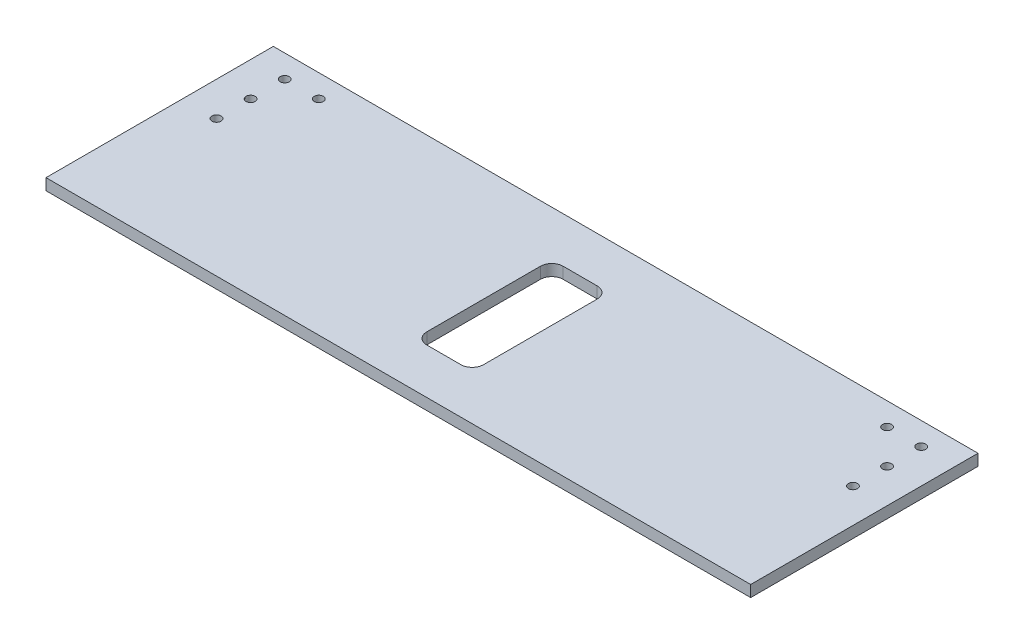
from build123d import *

# Parameters (mm, degrees)
SKETCH1_W           = 120
SKETCH1_H           = 95
SKETCH1_W_2         = 310
SKETCH1_H_2         = 100
BOSS_EXTRUDE1_DEPTH = 5
SKETCH2_R           = 2
SKETCH2_W           = 25
SKETCH2_H           = 60
CUT_EXTRUDE1_DEPTH  = 6
FILLET1_R           = 5
SKETCH5_W           = 80
SKETCH5_H           = 70
CUT_EXTRUDE2_DEPTH  = 5
CHAMFER1_SIZE       = 20
SKETCH6_W           = 95
SKETCH6_H           = 95
BOSS_EXTRUDE2_DEPTH = 5
SKETCH7_W           = 310
SKETCH7_H           = 95
CUT_EXTRUDE3_DEPTH  = 6


with BuildPart() as part:
    # Sketch1 → Boss-Extrude1 (new body)
    with BuildSketch(Plane(origin=(0, 0, 0), x_dir=(1, 0, 0), z_dir=(0, 1, 0))):
        with Locations((0, 97.5)):
            Rectangle(SKETCH1_W, SKETCH1_H)
        Rectangle(SKETCH1_W_2, SKETCH1_H_2)
    extrude(amount=BOSS_EXTRUDE1_DEPTH)

    # Sketch2 → Cut-Extrude1 (cut, through all)
    with BuildSketch(Plane(origin=(0, 5, 0), x_dir=(1, 0, 0), z_dir=(0, 1, 0))):
        with Locations((-140, 40)):
            Circle(SKETCH2_R)
        with Locations((-125, 40)):
            Circle(SKETCH2_R)
        with Locations((-140, 25)):
            Circle(SKETCH2_R)
        with Locations((-140, 10)):
            Circle(SKETCH2_R)
        with Locations((140, 10)):
            Circle(SKETCH2_R)
        with Locations((140, 25)):
            Circle(SKETCH2_R)
        with Locations((125, 40)):
            Circle(SKETCH2_R)
        with Locations((140, 40)):
            Circle(SKETCH2_R)
        with Locations((-50, 130)):
            Circle(SKETCH2_R)
        with Locations((50, 130)):
            Circle(SKETCH2_R)
        Rectangle(SKETCH2_W, SKETCH2_H)
    extrude(amount=-CUT_EXTRUDE1_DEPTH, mode=Mode.SUBTRACT)

    # Fillet1
    fillet1_edges = [part.edges().sort_by_distance(p)[0] for p in [
        (12.5, 2.5, -30),
        (12.5, 2.5, 30),
        (-12.5, 2.5, 30),
        (-12.5, 2.5, -30),
    ]]
    fillet(fillet1_edges, radius=FILLET1_R)

    # Sketch5 → Cut-Extrude2 (cut)
    with BuildSketch(Plane(origin=(0, 5, 0), x_dir=(1, 0, 0), z_dir=(0, 1, 0))):
        with Locations((0, 85)):
            Rectangle(SKETCH5_W, SKETCH5_H)
    extrude(amount=-CUT_EXTRUDE2_DEPTH, mode=Mode.SUBTRACT)

    # Chamfer1
    chamfer1_edges = [part.edges().sort_by_distance(p)[0] for p in [
        (40, 2.5, -50),
        (-40, 2.5, -50),
        (-40, 2.5, -120),
        (40, 2.5, -120),
    ]]
    chamfer(chamfer1_edges, length=CHAMFER1_SIZE)

    # Sketch6 → Boss-Extrude2 (add)
    with BuildSketch(Plane(origin=(0, 5, 0), x_dir=(1, 0, 0), z_dir=(0, 1, 0))):
        with Locations((107.5, 97.5)):
            Rectangle(SKETCH6_W, SKETCH6_H)
        with Locations((-107.5, 97.5)):
            Rectangle(SKETCH6_W, SKETCH6_H)
    extrude(amount=-BOSS_EXTRUDE2_DEPTH)

    # Sketch7 → Cut-Extrude3 (cut, through all)
    with BuildSketch(Plane(origin=(0, 5, 0), x_dir=(1, 0, 0), z_dir=(0, 1, 0))):
        with Locations((0, 97.5)):
            Rectangle(SKETCH7_W, SKETCH7_H)
    extrude(amount=-CUT_EXTRUDE3_DEPTH, mode=Mode.SUBTRACT)


solid = part.part
